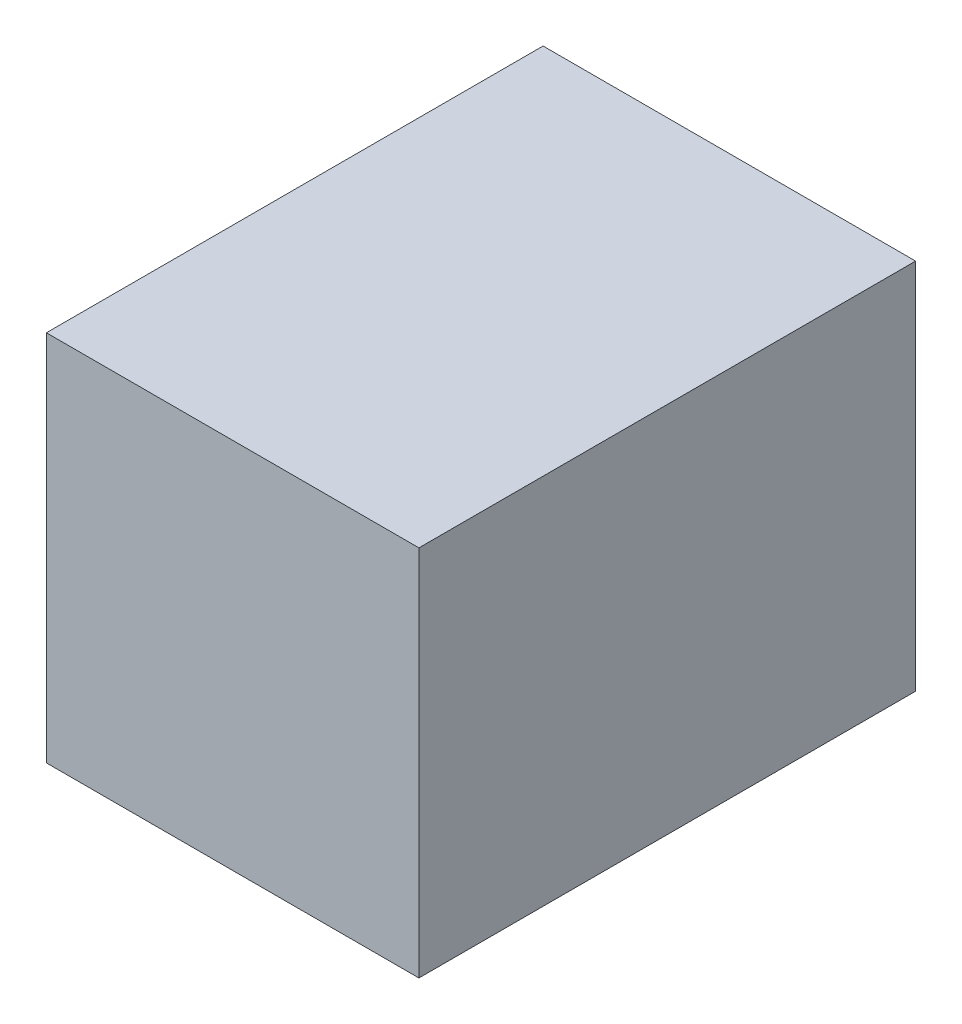
from build123d import *

# Parameters (mm, degrees)
SKETCH_1_W               = 15
SKETCH_1_H               = 15
EXTRUDE_1_DEPTH          = 20
SKETCH_2_W               = 12
SKETCH_2_H               = 12
CUT_EXTRUDE_1_DEPTH      = 17
CUT_EXTRUDE_1_DEPTH_BACK = 0.001


with BuildPart() as part:
    # 草图1 → 凸台-拉伸1 (new body)
    with BuildSketch(Plane.XY):
        Rectangle(SKETCH_1_W, SKETCH_1_H)
    extrude(amount=EXTRUDE_1_DEPTH)

    # 草图2 → 切除-拉伸1 (cut, two sides)
    with BuildSketch(Plane.XY) as cut_extrude_1_sk:
        Rectangle(SKETCH_2_W, SKETCH_2_H)
    extrude(amount=CUT_EXTRUDE_1_DEPTH, mode=Mode.SUBTRACT)
    extrude(cut_extrude_1_sk.sketch, amount=-CUT_EXTRUDE_1_DEPTH_BACK, mode=Mode.SUBTRACT)


solid = part.part
